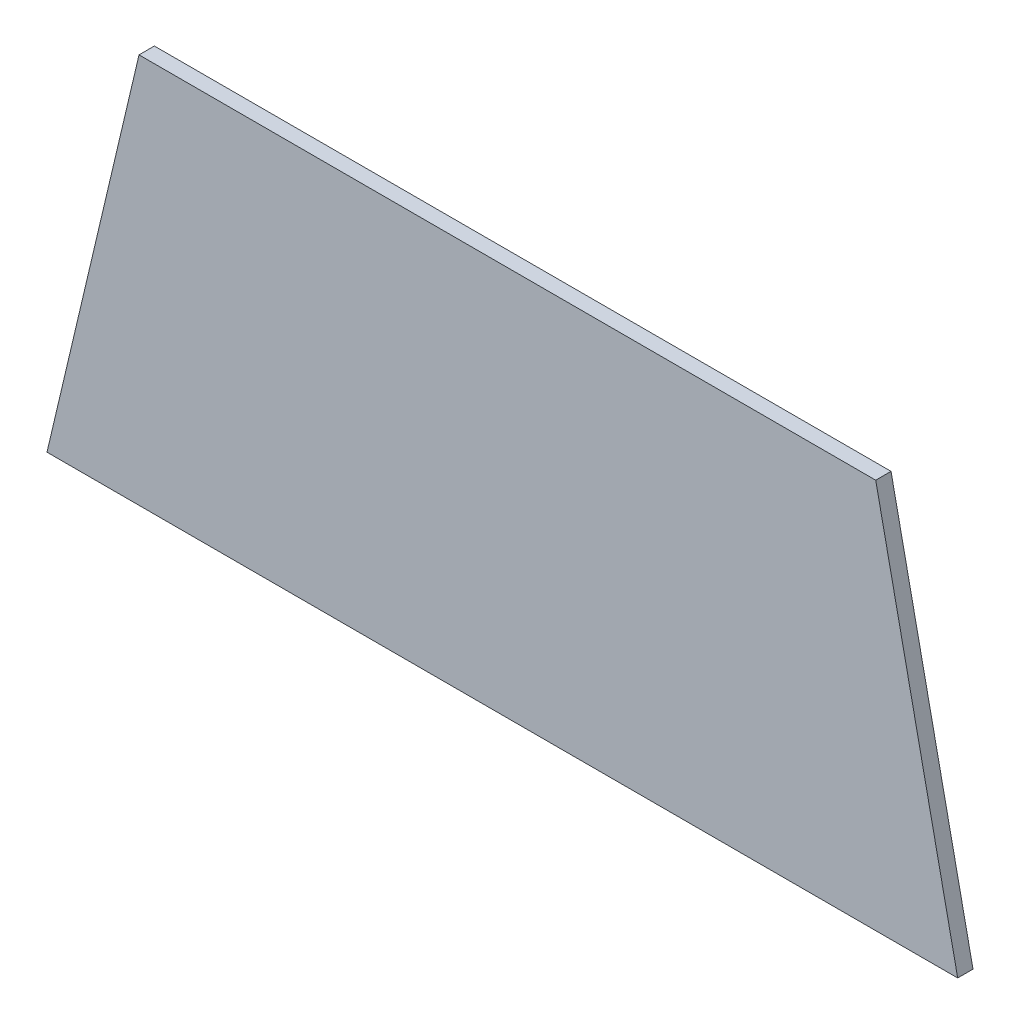
from build123d import *

# Parameters (mm, degrees)
BOSS_EXTRU_1_DEPTH = 3


with BuildPart() as part:
    # Esquisse1 → Boss.-Extru.1 (new body)
    with BuildSketch(Plane.XY):
        Polygon((96.313731619, -237.357033995), (80.270225398, -161.001919903), (-63.909016678, -161.001919903), (-81.921505864, -237.357033995), align=None)
    extrude(amount=BOSS_EXTRU_1_DEPTH)


solid = part.part
